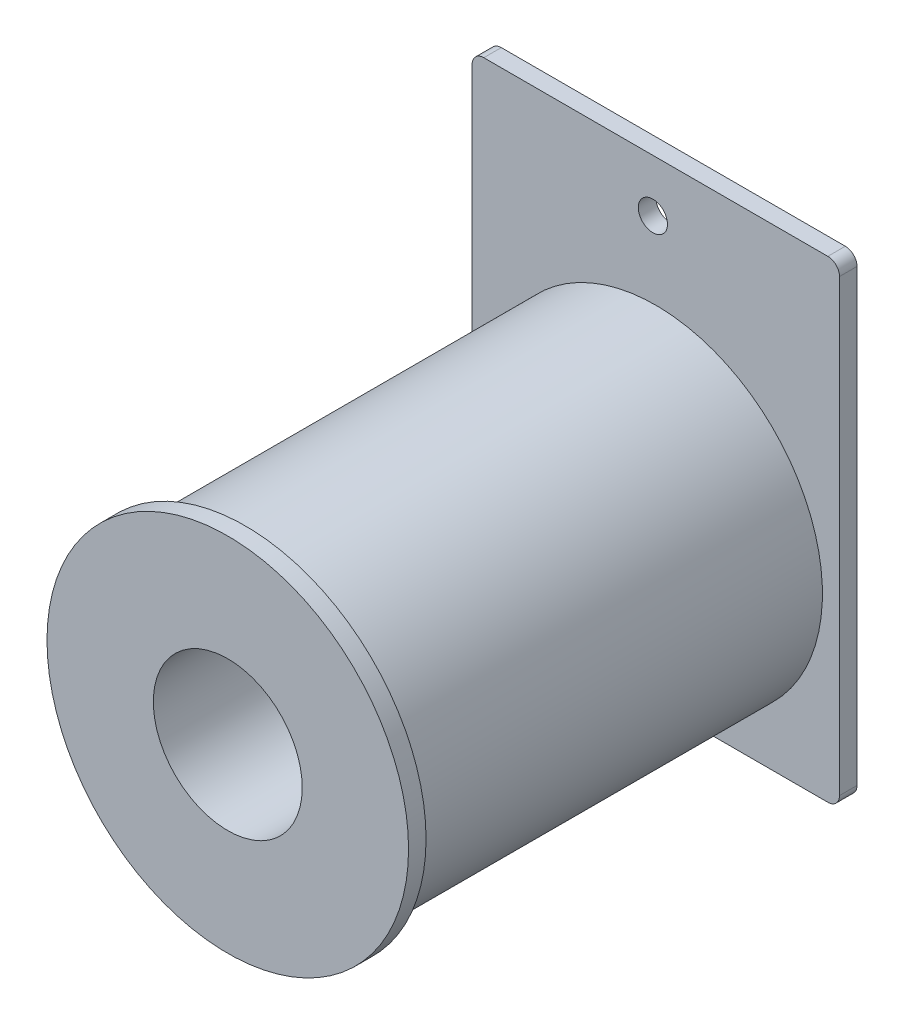
from build123d import *

# Parameters (mm, degrees)
ESQUISSE1_R             = 14.285
BOSS_EXTRU_1_DEPTH      = 35.2
ESQUISSE2_R             = 15.5
BOSS_EXTRU_2_DEPTH      = 1.5
BOSS_EXTRU_3_DEPTH      = 1.5
ESQUISSE3_R             = 6.385
ESQUISSE3_R_2           = 1.25
ENL_V_MAT_EXTRU_1_DEPTH = 39.2


with BuildPart() as part:
    # Esquisse1 → Boss.-Extru.1 (new body)
    with BuildSketch(Plane.XY):
        Circle(ESQUISSE1_R)
    extrude(amount=BOSS_EXTRU_1_DEPTH)

    # Esquisse2 → Boss.-Extru.2 (add)
    with BuildSketch(Plane.XY.offset(35.2)):
        Circle(ESQUISSE2_R)
    extrude(amount=BOSS_EXTRU_2_DEPTH)

    # Esquisse4 → Boss.-Extru.3 (add)
    with BuildSketch(Plane(origin=(0, 0, 0), x_dir=(-1, 0, 0), z_dir=(0, 0, -1))):
        with BuildLine():
            Line((-14.75, 25.285), (14.75, 25.285))
            ThreePointArc((14.75, 25.285), (15.457106781, 24.992106781), (15.75, 24.285))
            Line((15.75, 24.285), (15.75, -14.255))
            ThreePointArc((15.75, -14.255), (15.457106781, -14.962106781), (14.75, -15.255))
            Line((14.75, -15.255), (-14.75, -15.255))
            ThreePointArc((-14.75, -15.255), (-15.457106781, -14.962106781), (-15.75, -14.255))
            Line((-15.75, -14.255), (-15.75, 24.285))
            ThreePointArc((-15.75, 24.285), (-15.457106781, 24.992106781), (-14.75, 25.285))
        make_face()
    extrude(amount=BOSS_EXTRU_3_DEPTH)

    # Esquisse3 → Enlèv. mat.-Extru.1 (cut, through all)
    with BuildSketch(Plane.XY.offset(36.7)):
        Circle(ESQUISSE3_R)
        with Locations((-0.25, 20.785)):
            Circle(ESQUISSE3_R_2)
    extrude(amount=-ENL_V_MAT_EXTRU_1_DEPTH, mode=Mode.SUBTRACT)


solid = part.part
